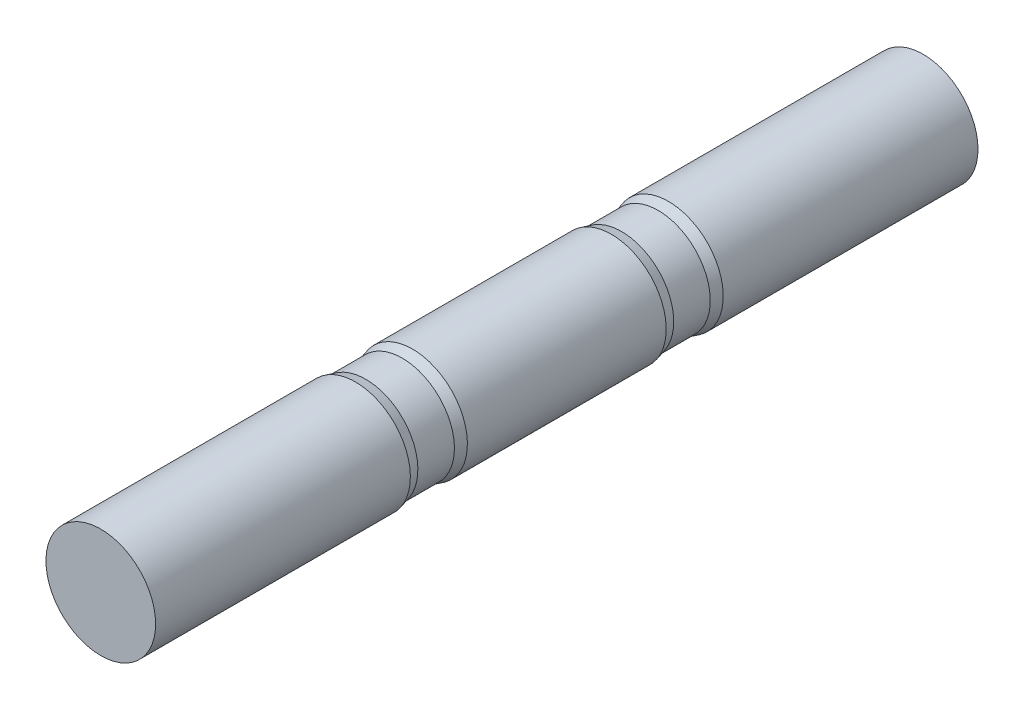
from build123d import *

# Parameters (mm, degrees)
SKETCH1_R           = 30
BOSS_EXTRUDE1_DEPTH = 225


with BuildPart() as part:
    # Sketch1 → Boss-Extrude1 (new body, symmetric)
    with BuildSketch(Plane.XY):
        Circle(SKETCH1_R)
    extrude(amount=BOSS_EXTRUDE1_DEPTH, both=True)

    # Sketch3 → Cut-Revolve1 (revolve, cut)
    with BuildSketch(Plane(origin=(0, 0, 0), x_dir=(0, 0, -1), z_dir=(1, 0, 0))):
        Polygon((-85.598076211, 30), (-80, 28.5), (-60, 28.5), (-54.401923789, 30), align=None)
        Polygon((85.598076211, 30), (54.401923789, 30), (60, 28.5), (80, 28.5), align=None)
    revolve(axis=Axis((0, 0, 225), (0, 0, -1)), mode=Mode.SUBTRACT)


solid = part.part
